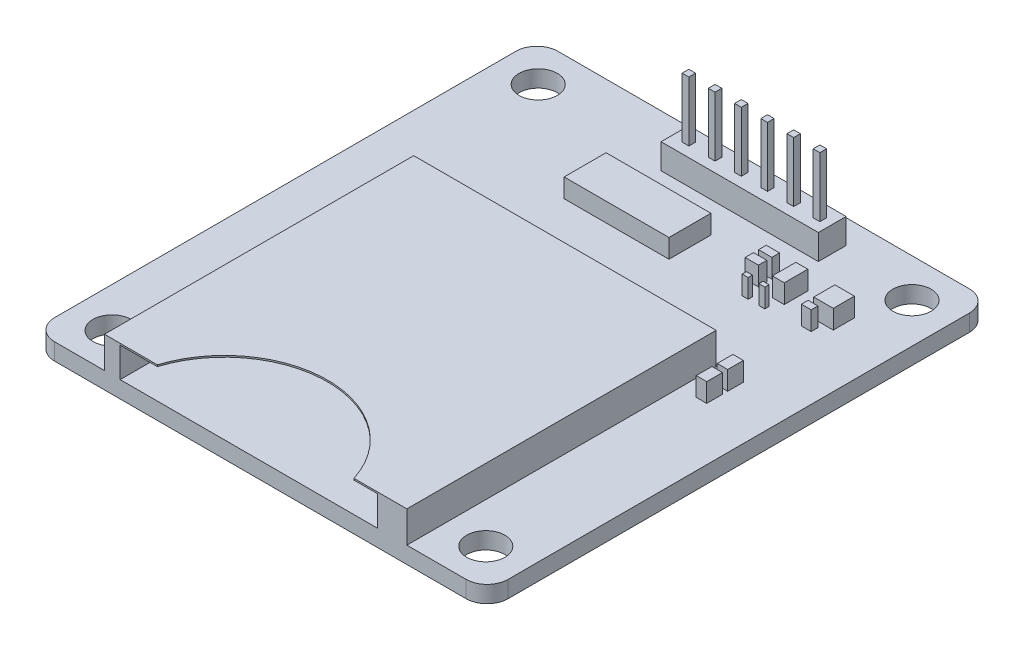
from build123d import *

# Parameters (mm, degrees)
SKETCH1_W               = 43.25
SKETCH1_H               = 48
SKETCH1_R               = 1.825
BOSS_EXTRUDE1_DEPTH     = 1.6
BOSS_EXTRUDE2_DEPTH     = 3
SKETCH3_W               = 24.55
SKETCH3_H               = 2.85
CUT_EXTRUDE1_DEPTH      = 21.6
SKETCH5_W               = 15
SKETCH5_H               = 2.65
BOSS_EXTRUDE4_DEPTH     = 2.4
SKETCH6_W               = 0.64
SKETCH6_H               = 0.64
BOSS_EXTRUDE5_DEPTH     = 5.7
FILLET1_R               = 2
CROQUIS1_W              = 1
CROQUIS1_H              = 1.5
CROQUIS1_W_2            = 10
CROQUIS1_H_2            = 4
CROQUIS1_W_3            = 1.267972753
CROQUIS1_H_3            = 0.734089488
CROQUIS1_H_4            = 0.798121905
CROQUIS1_W_4            = 1.14017415
CROQUIS1_H_5            = 2.245070142
CROQUIS1_W_5            = 1.862284445
CROQUIS1_H_6            = 2.017035312
CROQUIS1_W_6            = 0.931142223
CROQUIS1_H_7            = 0.646098685
CROQUIS1_W_7            = 0.570576299
CROQUIS1_H_8            = 0.403366405
SALIENTE_EXTRUIR1_DEPTH = 1.8


with BuildPart() as part:
    # Sketch1 → Boss-Extrude1 (new body)
    with BuildSketch(Plane(origin=(0, 0, 0), x_dir=(1, 0, 0), z_dir=(0, 1, 0))):
        with Locations((21.625, 24)):
            Rectangle(SKETCH1_W, SKETCH1_H)
        with Locations((3.8, 44.325)):
            Circle(SKETCH1_R, mode=Mode.SUBTRACT)
        with Locations((3.8, 3.675)):
            Circle(SKETCH1_R, mode=Mode.SUBTRACT)
        with Locations((39.45, 44.325)):
            Circle(SKETCH1_R, mode=Mode.SUBTRACT)
        with Locations((39.45, 3.675)):
            Circle(SKETCH1_R, mode=Mode.SUBTRACT)
    extrude(amount=BOSS_EXTRUDE1_DEPTH)

    # Sketch2 → Boss-Extrude2 (add)
    with BuildSketch(Plane(origin=(0, 1.6, 0), x_dir=(1, 0, 0), z_dir=(0, 1, 0))):
        with BuildLine():
            Line((6.75, 0), (11.8, 0))
            ThreePointArc((11.8, 0), (21.175, 6.86), (30.55, 0))
            Line((30.55, 0), (35.6, 0))
            Line((35.6, 0), (35.6, 29.5))
            Line((35.6, 29.5), (6.75, 29.5))
            Line((6.75, 29.5), (6.75, 0))
        make_face()
    extrude(amount=BOSS_EXTRUDE2_DEPTH)

    # Sketch3 → Cut-Extrude1 (cut)
    with BuildSketch(Plane.XY):
        with Locations((20.525, 3.025)):
            Rectangle(SKETCH3_W, SKETCH3_H)
    extrude(amount=-CUT_EXTRUDE1_DEPTH, mode=Mode.SUBTRACT)

    # Sketch5 → Boss-Extrude4 (add)
    with BuildSketch(Plane(origin=(0, 1.6, 0), x_dir=(1, 0, 0), z_dir=(0, 1, 0))):
        with Locations((24.293988912, 44.375)):
            Rectangle(SKETCH5_W, SKETCH5_H)
    extrude(amount=BOSS_EXTRUDE4_DEPTH)

    # Sketch6 → Boss-Extrude5 (add)
    with BuildSketch(Plane(origin=(0, 4, 0), x_dir=(1, 0, 0), z_dir=(0, 1, 0))):
        with Locations((18.153988912, 44.34)):
            Rectangle(SKETCH6_W, SKETCH6_H)
        with Locations((20.653988912, 44.34)):
            Rectangle(SKETCH6_W, SKETCH6_H)
        with Locations((23.153988912, 44.34)):
            Rectangle(SKETCH6_W, SKETCH6_H)
        with Locations((25.653988912, 44.34)):
            Rectangle(SKETCH6_W, SKETCH6_H)
        with Locations((28.153988912, 44.34)):
            Rectangle(SKETCH6_W, SKETCH6_H)
        with Locations((30.653988912, 44.34)):
            Rectangle(SKETCH6_W, SKETCH6_H)
    extrude(amount=BOSS_EXTRUDE5_DEPTH)

    # Fillet1
    fillet1_edges = [part.edges().sort_by_distance(p)[0] for p in [
        (0, 0.8, 0),
        (43.25, 0.8, 0),
        (43.25, 0.8, -48),
        (0, 0.8, -48),
    ]]
    fillet(fillet1_edges, radius=FILLET1_R)

    # Croquis1 → Saliente-Extruir1 (add)
    with BuildSketch(Plane(origin=(0, 1.6, 0), x_dir=(1, 0, 0), z_dir=(0, 1, 0))):
        with Locations((37.688468842, 26.759910401)):
            Rectangle(CROQUIS1_W, CROQUIS1_H)
        with Locations((19.480186858, 38.116576041)):
            Rectangle(CROQUIS1_W_2, CROQUIS1_H_2)
        with Locations((30.396581675, 39.749531297)):
            Rectangle(CROQUIS1_W_3, CROQUIS1_H_3)
        with Locations((30.396581675, 38.498601682)):
            Rectangle(CROQUIS1_W_3, CROQUIS1_H_4)
        with Locations((33.151840343, 38.99404097)):
            Rectangle(CROQUIS1_W_4, CROQUIS1_H_5)
        with Locations((37.237464381, 39.108058385)):
            Rectangle(CROQUIS1_W_5, CROQUIS1_H_6)
        with Locations((36.771893269, 37.244410117)):
            Rectangle(CROQUIS1_W_6, CROQUIS1_H_7)
        with Locations((32.867041418, 36.787844886)):
            Rectangle(CROQUIS1_W_7, CROQUIS1_H_8)
        with Locations((37.688468842, 28.759910401)):
            Rectangle(CROQUIS1_W, CROQUIS1_H)
        with Locations((31.277047992, 36.787844886)):
            Rectangle(CROQUIS1_W_7, CROQUIS1_H_8)
    extrude(amount=SALIENTE_EXTRUIR1_DEPTH)


solid = part.part
